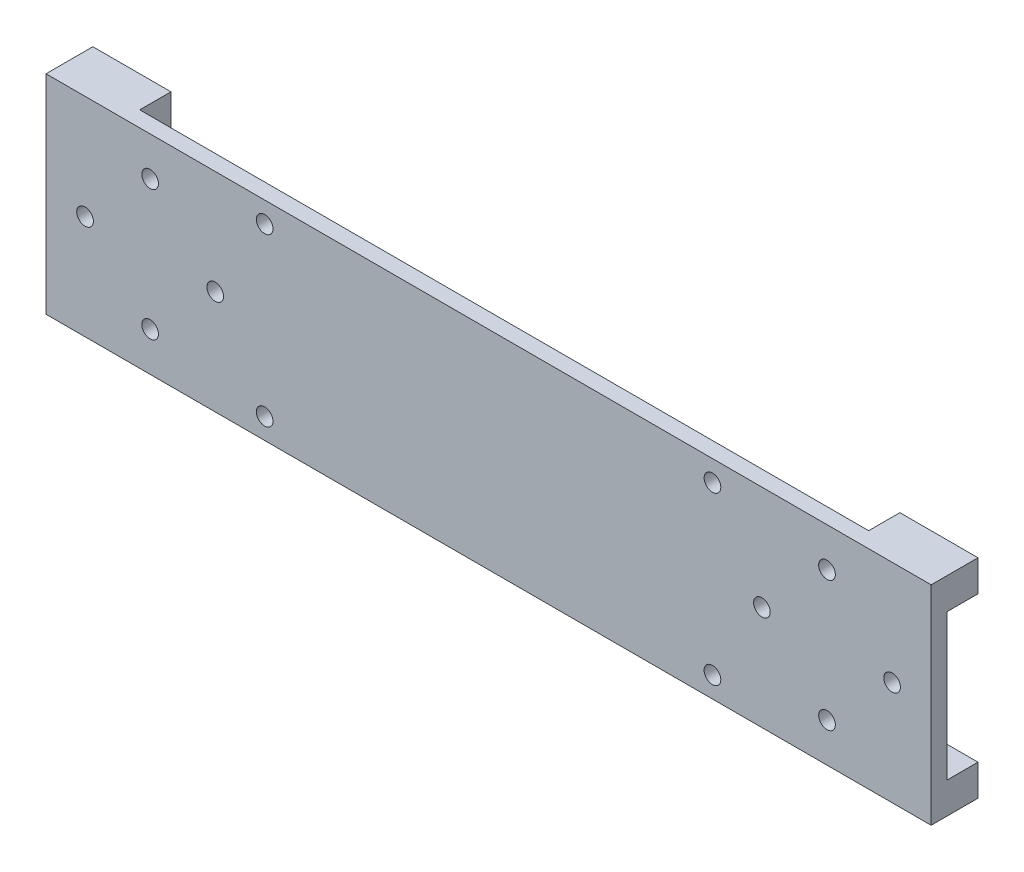
from build123d import *

# Parameters (mm, degrees)
SKETCH_1_W          = 170
SKETCH_1_H          = 40
SKETCH_1_R          = 1.6
EXTRUDE_1_DEPTH     = 3
SKETCH_2_R          = 1.6
CUT_EXTRUDE_1_DEPTH = 4
SKETCH_3_W          = 15
SKETCH_3_H          = 6
EXTRUDE_2_DEPTH     = 6


with BuildPart() as part:
    # 草图1 → 凸台-拉伸1 (new body)
    with BuildSketch(Plane.XY):
        with Locations((-6.503957784, -3.970976253)):
            Rectangle(SKETCH_1_W, SKETCH_1_H)
        with Locations((-71.503957784, 8.529023747)):
            Circle(SKETCH_1_R, mode=Mode.SUBTRACT)
        with Locations((-59.003957784, -3.970976253)):
            Circle(SKETCH_1_R, mode=Mode.SUBTRACT)
        with Locations((-71.503957784, -16.470976253)):
            Circle(SKETCH_1_R, mode=Mode.SUBTRACT)
        with Locations((-84.003957784, -3.970976253)):
            Circle(SKETCH_1_R, mode=Mode.SUBTRACT)
        with Locations((70.996042216, -3.970976253)):
            Circle(SKETCH_1_R, mode=Mode.SUBTRACT)
        with Locations((58.496042216, 8.529023747)):
            Circle(SKETCH_1_R, mode=Mode.SUBTRACT)
        with Locations((58.496042216, -16.470976253)):
            Circle(SKETCH_1_R, mode=Mode.SUBTRACT)
        with Locations((45.996042216, -3.970976253)):
            Circle(SKETCH_1_R, mode=Mode.SUBTRACT)
    extrude(amount=EXTRUDE_1_DEPTH)

    # 草图2 → 切除-拉伸1 (cut, through all)
    with BuildSketch(Plane(origin=(0, 0, 0), x_dir=(-1, 0, 0), z_dir=(0, 0, -1))):
        with Locations((-36.496042216, 12.029023747)):
            Circle(SKETCH_2_R)
        with Locations((-36.496042216, -19.970976253)):
            Circle(SKETCH_2_R)
        with Locations((49.503957784, 12.029023747)):
            Circle(SKETCH_2_R)
        with Locations((49.503957784, -19.970976253)):
            Circle(SKETCH_2_R)
    extrude(amount=-CUT_EXTRUDE_1_DEPTH, mode=Mode.SUBTRACT)

    # 草图3 → 凸台-拉伸2 (add)
    with BuildSketch(Plane(origin=(0, 0, 0), x_dir=(-1, 0, 0), z_dir=(0, 0, -1))):
        with Locations((-70.996042216, 13.029023747)):
            Rectangle(SKETCH_3_W, SKETCH_3_H)
        with Locations((-70.996042216, -20.970976253)):
            Rectangle(SKETCH_3_W, SKETCH_3_H)
        with Locations((84.003957784, 13.029023747)):
            Rectangle(SKETCH_3_W, SKETCH_3_H)
        with Locations((84.003957784, -20.970976253)):
            Rectangle(SKETCH_3_W, SKETCH_3_H)
    extrude(amount=EXTRUDE_2_DEPTH)


solid = part.part
